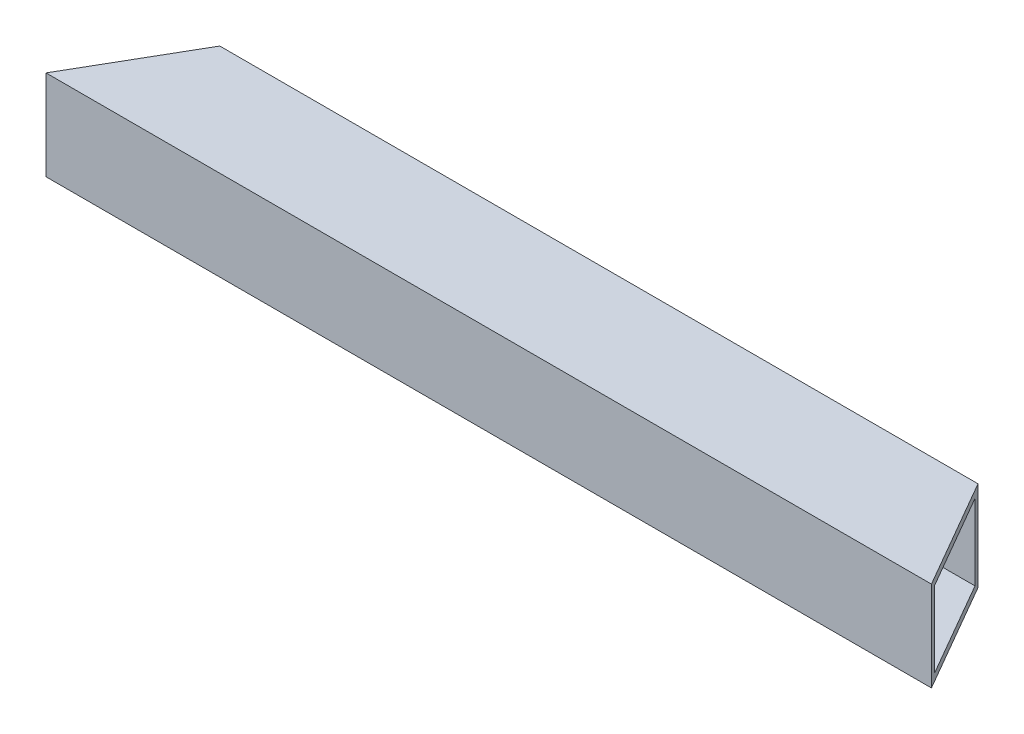
from build123d import *

# Parameters (mm, degrees)
BOSS_EXTRUDE1_DEPTH = 25.4
SHELL3_T            = -2


with BuildPart() as part:
    # Sketch1 → Boss-Extrude1 (new body)
    with BuildSketch(Plane(origin=(0, 0, 0), x_dir=(1, 0, 0), z_dir=(0, 1, 0))):
        Polygon((-90.556063278, -9.208067905), (-72.595551035, 21.900451829), (141.48342448, 21.900451829), (159.443936722, -9.208067905), align=None)
    extrude(amount=BOSS_EXTRUDE1_DEPTH)

    # Shell3
    shell3_openings = [part.faces().sort_by_distance(p)[0] for p in [
        (150.463680601, 12.7, -6.346191962),
    ]]
    offset(amount=SHELL3_T, openings=shell3_openings, kind=Kind.INTERSECTION)


solid = part.part
